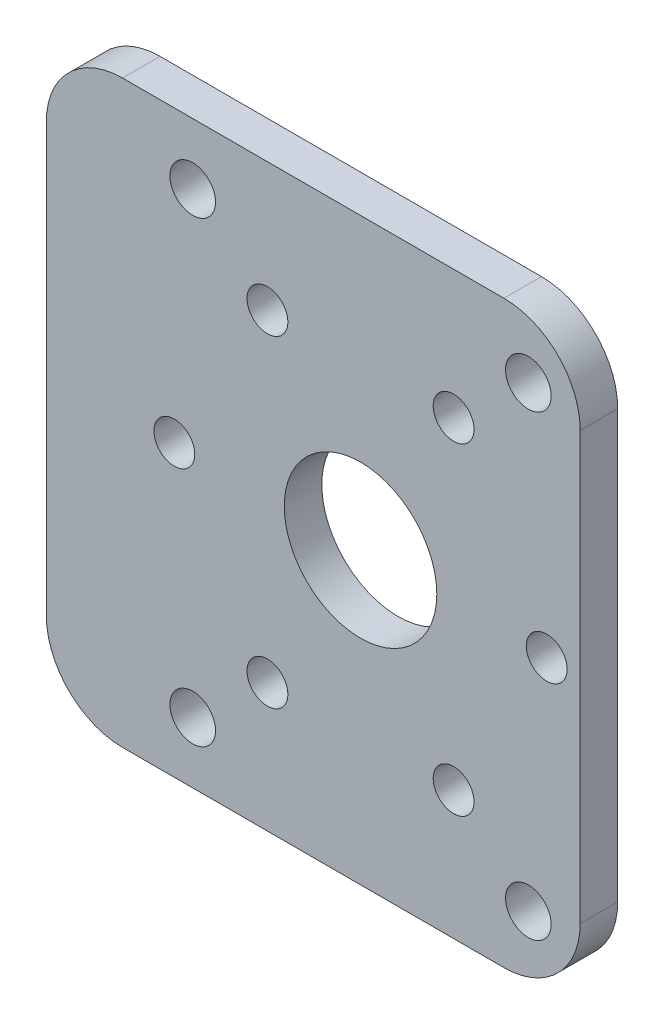
from build123d import *

# Parameters (mm, degrees)
SKETCH1_W                 = 44.45
SKETCH1_H                 = 48.26
BOSS_EXTRUDE1_DEPTH       = 3.1242
FILLET1_R                 = 6.35
F_6_CLEARANCE_HOLE1_D     = 3.7973
F_6_CLEARANCE_HOLE1_DEPTH = 5.08
F_6_CLEARANCE_HOLE1_TIP   = 1.140824014
SKETCH4_R                 = 6.35
CUT_EXTRUDE1_DEPTH        = 4.1242
M3_CLEARANCE_HOLE1_D      = 3.4


with BuildPart() as part:
    # Sketch1 → Boss-Extrude1 (new body)
    with BuildSketch(Plane.XY):
        with Locations((92.075, 24.13)):
            Rectangle(SKETCH1_W, SKETCH1_H)
    extrude(amount=BOSS_EXTRUDE1_DEPTH)

    # Fillet1
    fillet1_edges = [part.edges().sort_by_distance(p)[0] for p in [
        (69.85, 48.26, 1.5621),
        (114.3, 48.26, 1.5621),
        (114.3, 0, 1.5621),
        (69.85, 0, 1.5621),
    ]]
    fillet(fillet1_edges, radius=FILLET1_R)

    # #6 Clearance Hole1
    with Locations(Plane.XY.offset(3.1242)):
        with Locations((82.042, 43.18), (109.982, 43.18), (109.982, 5.08), (82.042, 5.08)):
            Hole(F_6_CLEARANCE_HOLE1_D / 2, depth=F_6_CLEARANCE_HOLE1_DEPTH)
            with Locations((0, 0, -(F_6_CLEARANCE_HOLE1_DEPTH + F_6_CLEARANCE_HOLE1_TIP / 2))):  # 118° drill point
                Cone(0, F_6_CLEARANCE_HOLE1_D / 2, F_6_CLEARANCE_HOLE1_TIP, mode=Mode.SUBTRACT)

    # Sketch4 → Cut-Extrude1 (cut, through all)
    with BuildSketch(Plane.XY.offset(3.1242)):
        with Locations((96.012, 24.13)):
            Circle(SKETCH4_R)
    extrude(amount=-CUT_EXTRUDE1_DEPTH, mode=Mode.SUBTRACT)

    # M3 Clearance Hole1 (through all)
    with Locations(Plane.XY.offset(3.1242)):
        with Locations((111.512, 24.13), (103.762, 10.706606241), (88.262, 10.706606241), (80.512, 24.13), (88.262, 37.553393759), (103.762, 37.553393759), (96.012, 24.13)):
            Hole(M3_CLEARANCE_HOLE1_D / 2)


solid = part.part
